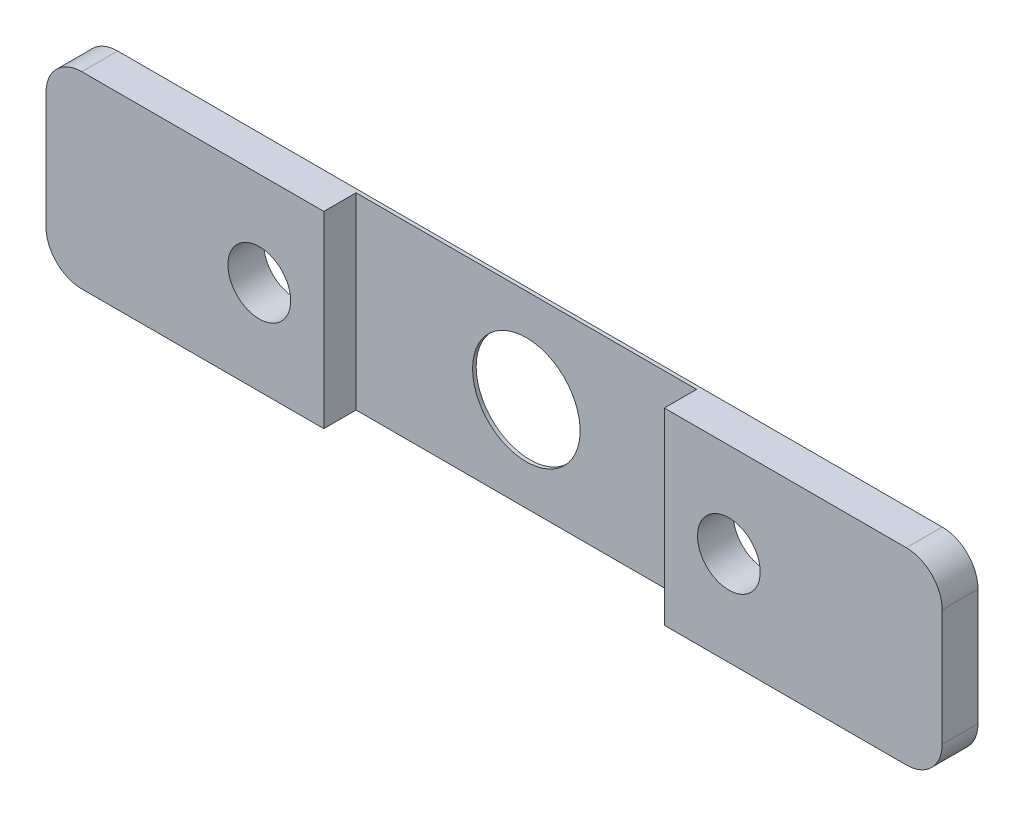
from build123d import *

# Parameters (mm, degrees)
SKETCH_1_W          = 50
SKETCH_1_H          = 10.5
SKETCH_1_R          = 1.75
EXTRUDE_1_DEPTH     = 2
FILLET_1_R          = 2
SKETCH_2_W          = 19
SKETCH_2_H          = 10.5
CUT_EXTRUDE_1_DEPTH = 1.8
SKETCH_3_R          = 3
CUT_EXTRUDE_2_DEPTH = 3


with BuildPart() as part:
    # ｽｹｯﾁ1 → ﾎﾞｽ - 押し出し1 (new body)
    with BuildSketch(Plane.XY):
        Rectangle(SKETCH_1_W, SKETCH_1_H)
        with Locations((13.1, 0)):
            Circle(SKETCH_1_R, mode=Mode.SUBTRACT)
        with Locations((-13.1, 0)):
            Circle(SKETCH_1_R, mode=Mode.SUBTRACT)
    extrude(amount=EXTRUDE_1_DEPTH)

    # ﾌｨﾚｯﾄ1
    fillet_1_edges = [part.edges().sort_by_distance(p)[0] for p in [
        (25, -5.25, 1),
        (-25, -5.25, 1),
        (-25, 5.25, 1),
        (25, 5.25, 1),
    ]]
    fillet(fillet_1_edges, radius=FILLET_1_R)

    # ｽｹｯﾁ2 → ｶｯﾄ - 押し出し1 (cut)
    with BuildSketch(Plane.XY.offset(2)):
        Rectangle(SKETCH_2_W, SKETCH_2_H)
    extrude(amount=-CUT_EXTRUDE_1_DEPTH, mode=Mode.SUBTRACT)

    # ｽｹｯﾁ3 → ｶｯﾄ - 押し出し2 (cut, through all)
    with BuildSketch(Plane(origin=(0, 0, 0), x_dir=(-1, 0, 0), z_dir=(0, 0, -1))):
        Circle(SKETCH_3_R)
    extrude(amount=-CUT_EXTRUDE_2_DEPTH, mode=Mode.SUBTRACT)


solid = part.part
